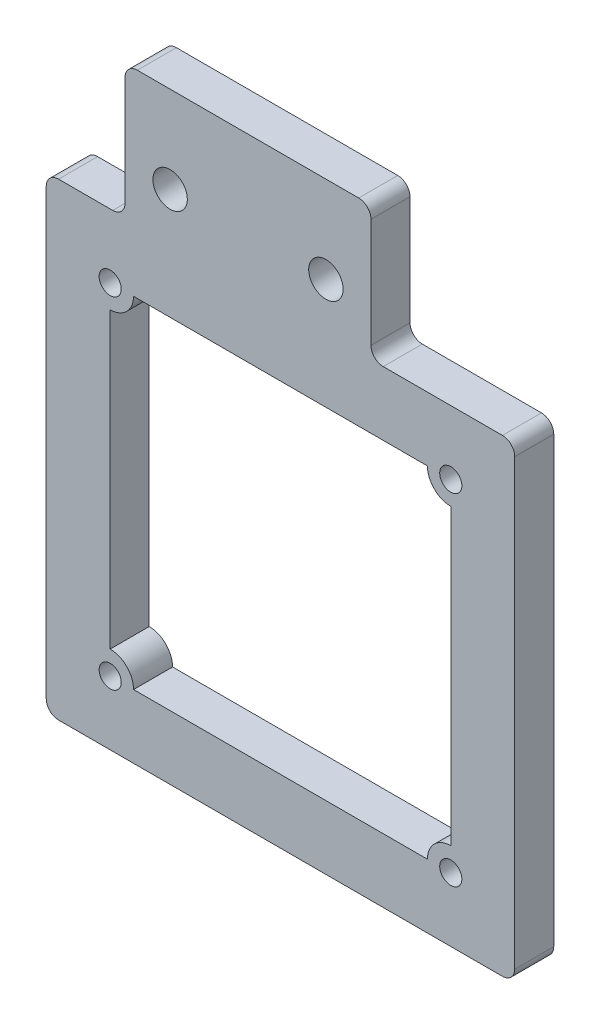
from build123d import *

# Parameters (mm, degrees)
SKETCH1_R           = 0.9
SKETCH1_R_2         = 1.4
BOSS_EXTRUDE1_DEPTH = 3.175
FILLET1_R           = 1


with BuildPart() as part:
    # Sketch1 → Boss-Extrude1 (new body)
    with BuildSketch(Plane.XY):
        Polygon((31.690894529, -38.1), (31.690894529, 0), (20, 0), (20, 10.87553853), (0, 10.87553853), (0, 0), (-6.409105471, 0), (-6.409105471, -38.1), align=None)
        with Locations((26.490894529, -32.9)):
            Circle(SKETCH1_R, mode=Mode.SUBTRACT)
        with Locations((-1.209105471, -32.9)):
            Circle(SKETCH1_R, mode=Mode.SUBTRACT)
        with Locations((-1.209105471, -5.2)):
            Circle(SKETCH1_R, mode=Mode.SUBTRACT)
        with Locations((26.490894529, -5.2)):
            Circle(SKETCH1_R, mode=Mode.SUBTRACT)
        with Locations((16.335044769, 3.811593223)):
            Circle(SKETCH1_R_2, mode=Mode.SUBTRACT)
        with Locations((3.664955231, 3.811593223)):
            Circle(SKETCH1_R_2, mode=Mode.SUBTRACT)
        with BuildLine():
            Line((26.490894529, -7.1), (26.490894529, -31))
            ThreePointArc((26.490894529, -31), (25.147391645, -31.556497116), (24.590894529, -32.9))
            Line((24.590894529, -32.9), (0.690894529, -32.9))
            ThreePointArc((0.690894529, -32.9), (0.134397413, -31.556497116), (-1.209105471, -31))
            Line((-1.209105471, -31), (-1.209105471, -7.1))
            ThreePointArc((-1.209105471, -7.1), (0.134397413, -6.543502884), (0.690894529, -5.2))
            Line((0.690894529, -5.2), (24.590894529, -5.2))
            ThreePointArc((24.590894529, -5.2), (25.147391645, -6.543502884), (26.490894529, -7.1))
        make_face(mode=Mode.SUBTRACT)
    extrude(amount=BOSS_EXTRUDE1_DEPTH)

    # Fillet1
    fillet1_edges = [part.edges().sort_by_distance(p)[0] for p in [
        (20, 10.87553853, 1.5875),
        (20, 0, 1.5875),
        (31.690894529, 0, 1.5875),
        (31.690894529, -38.1, 1.5875),
        (-6.409105471, -38.1, 1.5875),
        (-6.409105471, 0, 1.5875),
        (0, 0, 1.5875),
        (0, 10.87553853, 1.5875),
    ]]
    fillet(fillet1_edges, radius=FILLET1_R)


solid = part.part
